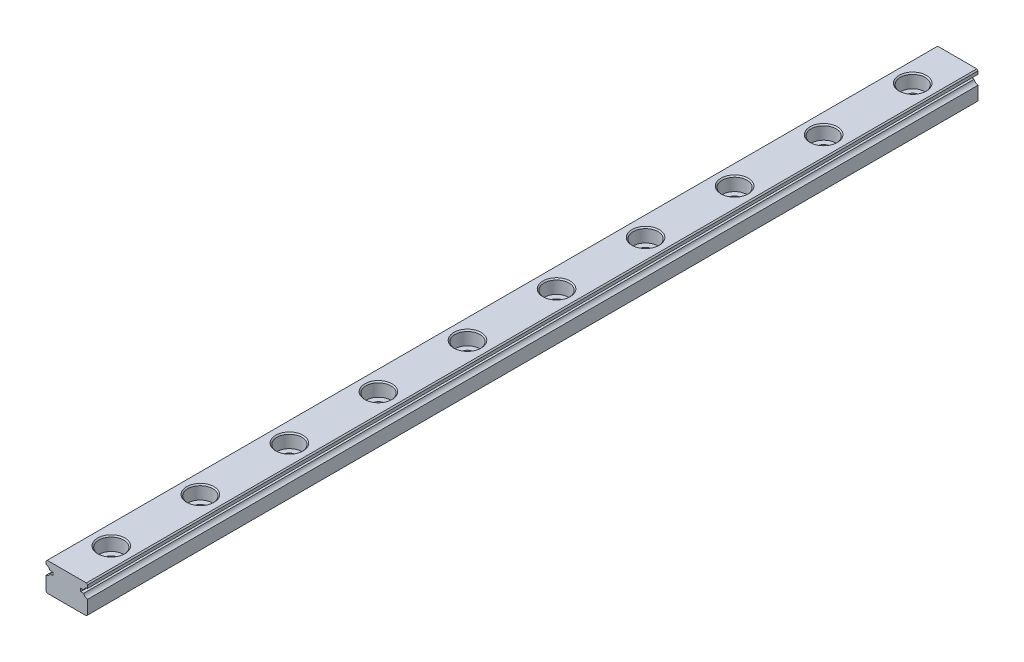
from build123d import *

# Parameters (mm, degrees)
EXTRUDE1_DEPTH             = 150
EXTRUDE2_REACH             = 152.118
SKETCH2_R                  = 1.2
SKETCH_R                   = 2.1
SKETCH_R_2                 = 1.2
EXTRUDE4_DEPTH             = 2.3
CHAMFER1_SIZE              = 0.2
LPATTERN1_COUNT            = 10
LPATTERN1_PITCH            = 15
CHAMFER1_OF_LPATTERN1_SIZE = 0.2


with BuildPart() as part:
    # Sketch1 → Extrude1 (new body)
    with BuildSketch(Plane.XY):
        with BuildLine():
            Line((-3.3, -2.4), (3.3, -2.4))
            Line((3.3, -2.4), (3.5, -2.2))
            Line((3.5, -2.2), (3.5, 0.106274607))
            ThreePointArc((3.5, 0.106274607), (3.091294745, 0.282570681), (2.840065792, 0.65))
            Line((2.840065792, 0.65), (2.340065792, 0.65))
            Line((2.340065792, 0.65), (2.340065792, 1.15))
            Line((2.340065792, 1.15), (2.840065792, 1.15))
            ThreePointArc((2.840065792, 1.15), (3.091294745, 1.517429319), (3.5, 1.693725393))
            Line((3.5, 1.693725393), (3.5, 2.2))
            Line((3.5, 2.2), (3.3, 2.4))
            Line((3.3, 2.4), (-3.3, 2.4))
            Line((-3.3, 2.4), (-3.5, 2.2))
            Line((-3.5, 2.2), (-3.5, 1.693725393))
            ThreePointArc((-3.5, 1.693725393), (-3.091294745, 1.517429319), (-2.840065792, 1.15))
            Line((-2.840065792, 1.15), (-2.340065792, 1.15))
            Line((-2.340065792, 1.15), (-2.340065792, 0.65))
            Line((-2.340065792, 0.65), (-2.840065792, 0.65))
            ThreePointArc((-2.840065792, 0.65), (-3.091294745, 0.282570681), (-3.5, 0.106274607))
            Line((-3.5, 0.106274607), (-3.5, -2.2))
            Line((-3.5, -2.2), (-3.3, -2.4))
        make_face()
    extrude(amount=EXTRUDE1_DEPTH)

    # Sketch2 → Extrude2 (cut, up to next)
    with BuildSketch(Plane(origin=(0, 2.4, 0), x_dir=(1, 0, 0), z_dir=(0, 1, 0)), mode=Mode.PRIVATE) as extrude2_sk1:
        with Locations((0, -7.5)):
            Circle(SKETCH2_R)
    extrude2_tool1 = extrude(extrude2_sk1.sketch, amount=-EXTRUDE2_REACH, mode=Mode.PRIVATE) & part.part
    extrude2 = extrude2_tool1.solids().sort_by_distance((0, 2.4, 7.5))[0]
    add(extrude2, mode=Mode.SUBTRACT)

    # Sketch → Extrude4 (cut)
    with BuildSketch(Plane(origin=(0, 2.4, 0), x_dir=(1, 0, 0), z_dir=(0, 1, 0))):
        with Locations((0, -7.5)):
            Circle(SKETCH_R)
        with Locations((0, -7.5)):
            Circle(SKETCH_R_2, mode=Mode.SUBTRACT)
    extrude4 = extrude(amount=-EXTRUDE4_DEPTH, mode=Mode.SUBTRACT)

    # Chamfer1
    chamfer1_edges = [part.edges().sort_by_distance(p)[0] for p in [
        (-1.2, -2.4, 7.5),
        (-2.1, 2.4, 7.5),
    ]]
    chamfer(chamfer1_edges, length=CHAMFER1_SIZE)

    # LPattern1: Extrude2, Extrude4 ×10
    with Locations(*[(0, 0, i * LPATTERN1_PITCH) for i in range(1, LPATTERN1_COUNT)]):
        add(extrude2, mode=Mode.SUBTRACT)
        add(extrude4, mode=Mode.SUBTRACT)

    # Chamfer1 of LPattern1
    chamfer1_of_lpattern1_edges = [part.edges().sort_by_distance(p)[0] for p in [
        (-1.2, -2.4, 22.5),
        (-2.1, 2.4, 22.5),
        (-1.2, -2.4, 37.5),
        (-2.1, 2.4, 37.5),
        (-1.2, -2.4, 52.5),
        (-2.1, 2.4, 52.5),
        (-1.2, -2.4, 67.5),
        (-2.1, 2.4, 67.5),
        (-1.2, -2.4, 82.5),
        (-2.1, 2.4, 82.5),
        (-1.2, -2.4, 97.5),
        (-2.1, 2.4, 97.5),
        (-1.2, -2.4, 112.5),
        (-2.1, 2.4, 112.5),
        (-1.2, -2.4, 127.5),
        (-2.1, 2.4, 127.5),
        (-1.2, -2.4, 142.5),
        (-2.1, 2.4, 142.5),
    ]]
    chamfer(chamfer1_of_lpattern1_edges, length=CHAMFER1_OF_LPATTERN1_SIZE)


solid = part.part
